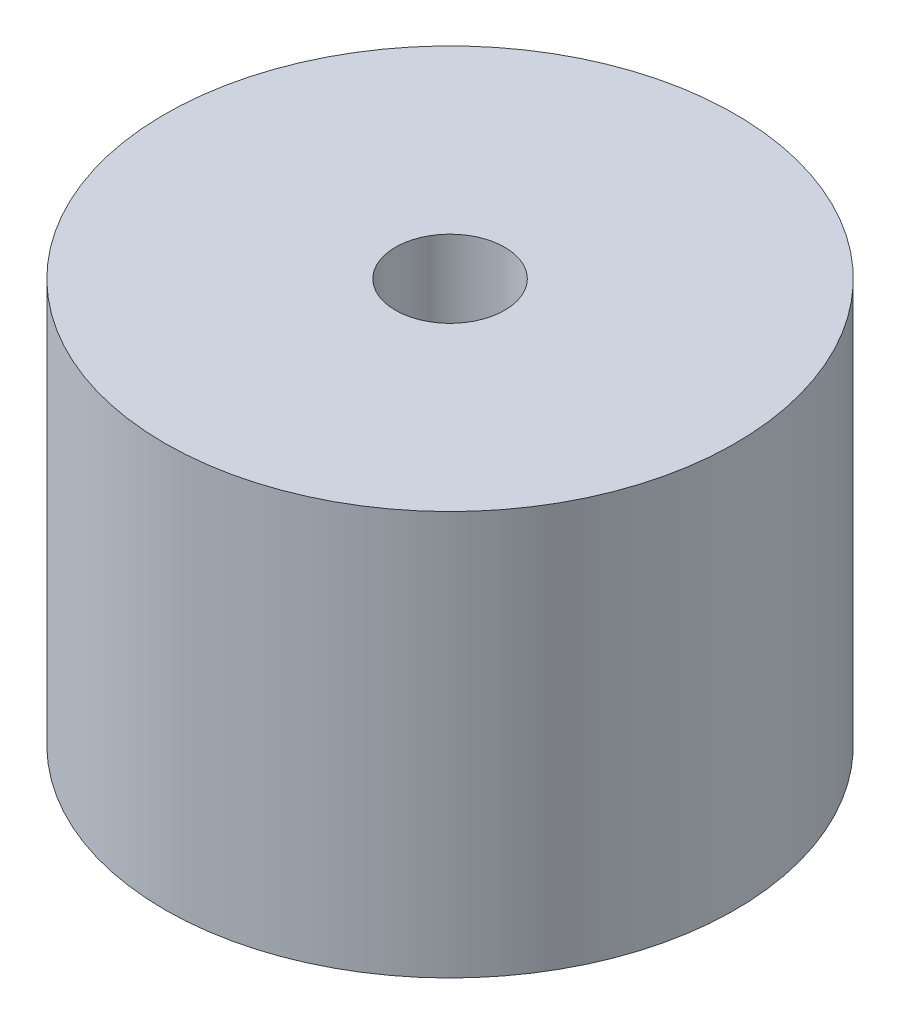
from build123d import *

# Parameters (mm, degrees)
SKETCH1_R           = 6
BOSS_EXTRUDE1_DEPTH = 8.5
SKETCH2_R           = 1.15
CUT_EXTRUDE1_DEPTH  = 3


with BuildPart() as part:
    # Sketch1 → Boss-Extrude1 (new body)
    with BuildSketch(Plane(origin=(0, 0, 0), x_dir=(1, 0, 0), z_dir=(0, 1, 0))):
        Circle(SKETCH1_R)
    extrude(amount=BOSS_EXTRUDE1_DEPTH)

    # Sketch2 → Cut-Extrude1 (cut)
    with BuildSketch(Plane(origin=(0, 8.5, 0), x_dir=(1, 0, 0), z_dir=(0, 1, 0))):
        Circle(SKETCH2_R)
    extrude(amount=-CUT_EXTRUDE1_DEPTH, mode=Mode.SUBTRACT)


solid = part.part
